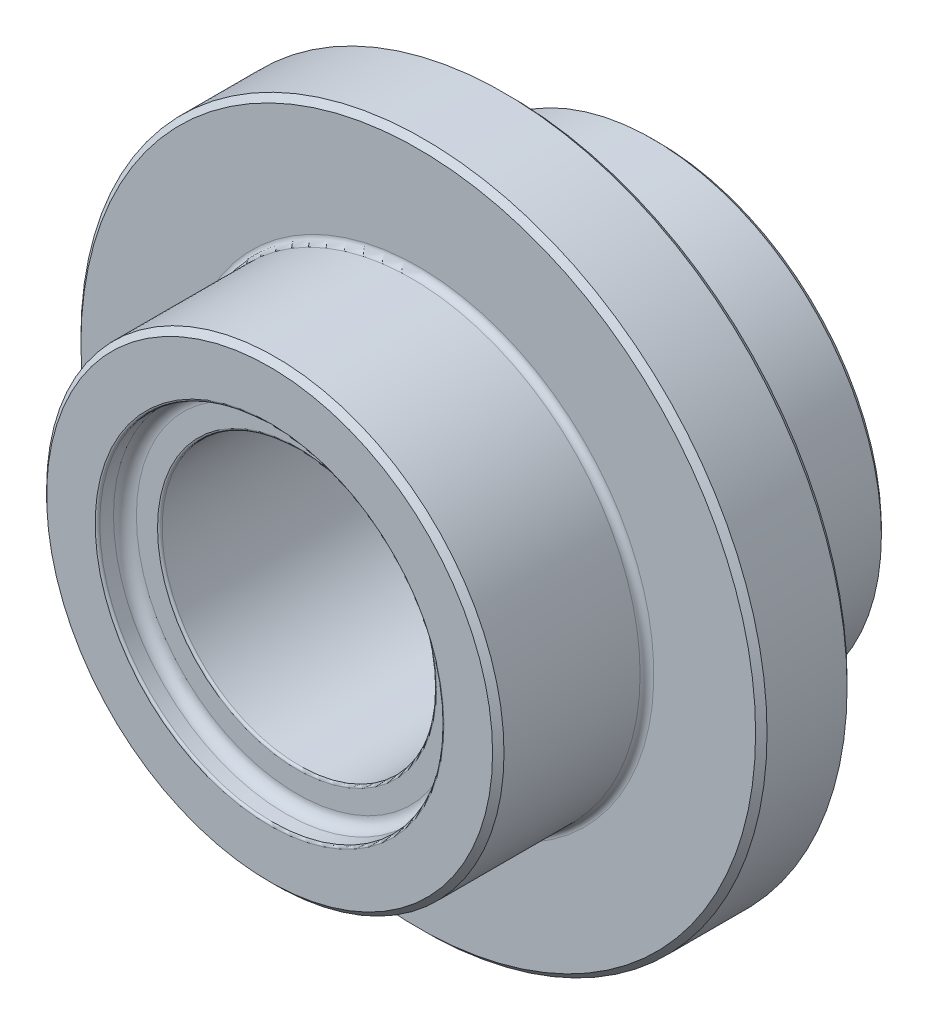
from build123d import *

# Parameters (mm, degrees)
SKETCH1_R           = 20
BOSS_EXTRUDE1_DEPTH = 13
SKETCH2_R           = 30
BOSS_EXTRUDE2_DEPTH = 8
BOSS_EXTRUDE3_START = 13
SKETCH3_R           = 20
BOSS_EXTRUDE3_DEPTH = 13
CUT_EXTRUDE1_REACH  = 56.369
SKETCH4_R           = 12
SKETCH5_R           = 15.05
CUT_EXTRUDE2_DEPTH  = 2.4
CHAMFER1_SIZE       = 0.5
FILLET1_R           = 0.6
FILLET2_R           = 0.2
FILLET3_R           = 1


with BuildPart() as part:
    # Sketch1 → Boss-Extrude1 (new body)
    with BuildSketch(Plane.XY):
        Circle(SKETCH1_R)
    extrude(amount=BOSS_EXTRUDE1_DEPTH)

    # Sketch2 → Boss-Extrude2 (add)
    with BuildSketch(Plane(origin=(0, 0, 0), x_dir=(-1, 0, 0), z_dir=(0, 0, -1))):
        Circle(SKETCH2_R)
    extrude(amount=BOSS_EXTRUDE2_DEPTH)

    # Sketch3 → Boss-Extrude3 (add)
    with BuildSketch(Plane(origin=(0, 0, -8), x_dir=(-1, 0, 0), z_dir=(0, 0, -1)).offset(BOSS_EXTRUDE3_START)):
        Circle(SKETCH3_R)
    extrude(amount=-BOSS_EXTRUDE3_DEPTH)

    # Sketch4 → Cut-Extrude1 (cut, up to next)
    with BuildSketch(Plane.XY.offset(13), mode=Mode.PRIVATE) as cut_extrude1_sk1:
        Circle(SKETCH4_R)
    cut_extrude1_tool1 = extrude(cut_extrude1_sk1.sketch, amount=-CUT_EXTRUDE1_REACH, mode=Mode.PRIVATE) & part.part
    add(cut_extrude1_tool1.solids().sort_by_distance((0, 0, 13))[0], mode=Mode.SUBTRACT)

    # Sketch5 → Cut-Extrude2 (cut)
    with BuildSketch(Plane.XY.offset(13)):
        Circle(SKETCH5_R)
    extrude(amount=-CUT_EXTRUDE2_DEPTH, mode=Mode.SUBTRACT)

    # Chamfer1
    chamfer1_edges = [part.edges().sort_by_distance(p)[0] for p in [
        (-12, 0, -21),
        (20, 0, -21),
        (30, 0, -8),
        (30, 0, 0),
        (-20, 0, 13),
    ]]
    chamfer(chamfer1_edges, length=CHAMFER1_SIZE)

    # Fillet1
    fillet1_edges = [part.edges().sort_by_distance(p)[0] for p in [
        (-20, 0, 0),
        (20, 0, -8),
    ]]
    fillet(fillet1_edges, radius=FILLET1_R)

    # Fillet2
    fillet2_edges = [part.edges().sort_by_distance(p)[0] for p in [
        (-15.05, 0, 13),
        (-12, 0, 10.6),
    ]]
    fillet(fillet2_edges, radius=FILLET2_R)

    # Fillet3
    fillet3_edges = [part.edges().sort_by_distance(p)[0] for p in [
        (-15.05, 0, 10.6),
    ]]
    fillet(fillet3_edges, radius=FILLET3_R)


solid = part.part
